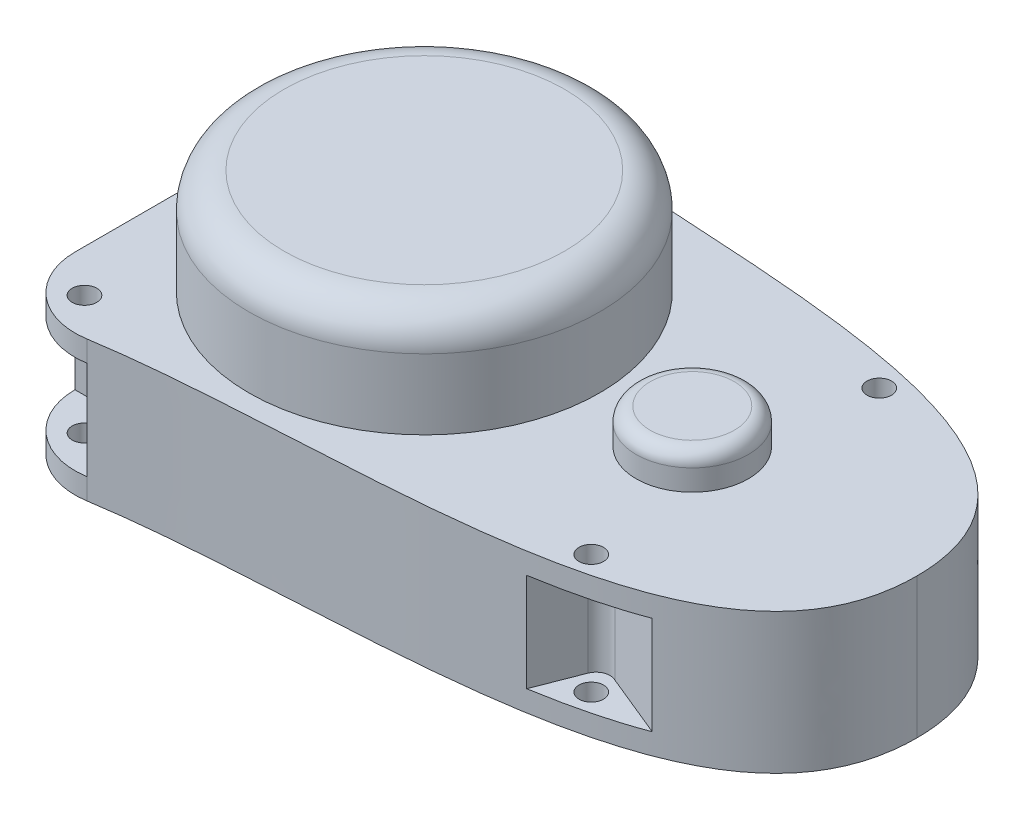
from build123d import *

# Parameters (mm, degrees)
BOSS_EXTRUDE2_DEPTH = 20
CUT_EXTRUDE1_START  = 3
CUT_EXTRUDE1_DEPTH  = 14
SKETCH3_3_R         = 1.75
CUT_EXTRUDE2_DEPTH  = 20
CUT_EXTRUDE3_START  = 3
CUT_EXTRUDE3_DEPTH  = 14
SKETCH4_3_R         = 1.75
CUT_EXTRUDE4_DEPTH  = 20
SKETCH5_R           = 25
BOSS_EXTRUDE3_DEPTH = 15
SKETCH5_3_R         = 8
BOSS_EXTRUDE4_DEPTH = 5
FILLET1_R           = 5
FILLET2_R           = 2


with BuildPart() as part:
    # Sketch2 → Boss-Extrude2 (new body)
    with BuildSketch(Plane(origin=(0, 0, 0), x_dir=(1, 0, 0), z_dir=(0, 1, 0))):
        with BuildLine():
            ThreePointArc((-46.431276572, 29.876188881), (-54.492794688, 27.605499138), (-58, 20))
            Line((-58, 20), (-58, -20))
            ThreePointArc((-58, -20), (-54.492794688, -27.605499138), (-46.431276572, -29.876188881))
            add(Edge.make_bspline(
                [(-46.431276572, -29.876188881), (-13.909309772, -24.710433965), (42, -31.730945936), (42, 31.730945936), (-13.909309772, 24.710433965), (-46.431276572, 29.876188881)],
                knots=[0, 0, 0, 0, 1, 1, 2, 2, 2, 2], degree=3))
        make_face()
    extrude(amount=BOSS_EXTRUDE2_DEPTH)

    # Sketch3 → Cut-Extrude1 (cut)
    with BuildSketch(Plane(origin=(0, 0, 0), x_dir=(1, 0, 0), z_dir=(0, 1, 0)).offset(CUT_EXTRUDE1_START)):
        with BuildLine():
            ThreePointArc((-46.431276572, 29.876188881), (-54.492794688, 27.605499138), (-58, 20))
            Line((-58, 20), (-49.70739476, 20))
            ThreePointArc((-49.70739476, 20), (-48.408835822, 20.478900172), (-47.732156984, 21.686255314))
            Line((-47.732156984, 21.686255314), (-46.431276572, 29.876188881))
        make_face()
        with BuildLine():
            Line((-49.70739476, -20), (-58, -20))
            ThreePointArc((-58, -20), (-54.492794688, -27.605499138), (-46.431276572, -29.876188881))
            Line((-46.431276572, -29.876188881), (-47.732156984, -21.686255314))
            ThreePointArc((-47.732156984, -21.686255314), (-48.408835822, -20.478900172), (-49.70739476, -20))
        make_face()
    extrude(amount=CUT_EXTRUDE1_DEPTH, mode=Mode.SUBTRACT)

    # Sketch3_3 → Cut-Extrude2 (cut)
    with BuildSketch(Plane(origin=(0, 0, 0), x_dir=(1, 0, 0), z_dir=(0, 1, 0))):
        with Locations((-51.979872901, 24.661924698)):
            Circle(SKETCH3_3_R)
        with Locations((-51.979872901, -24.661924698)):
            Circle(SKETCH3_3_R)
    extrude(amount=CUT_EXTRUDE2_DEPTH, mode=Mode.SUBTRACT)

    # Sketch4 → Cut-Extrude3 (cut)
    with BuildSketch(Plane(origin=(0, 0, 0), x_dir=(1, 0, 0), z_dir=(0, 1, 0)).offset(CUT_EXTRUDE3_START)):
        with BuildLine():
            Line((13.558094658, -18.415384316), (11.112598696, -24.715384316))
            add(Edge.make_bspline(
                [(11.112598695, -24.715384316), (16.304251166, -23.843854524), (21.135081496, -22.680661048), (25.361920748, -21.06959966)],
                knots=[0.510512009, 0.510512009, 0.510512009, 0.510512009, 0.655795995, 0.655795995, 0.655795995, 0.655795995], degree=3))
            Line((25.361920749, -21.06959966), (16.361920749, -17.373449023))
            ThreePointArc((16.361920749, -17.373449023), (14.725878749, -17.264380548), (13.558094658, -18.415384316))
        make_face()
        with BuildLine():
            add(Edge.make_bspline(
                [(11.112598695, 24.715384316), (16.304251166, 23.843854524), (21.135081496, 22.680661048), (25.361920748, 21.06959966)],
                knots=[0.510512009, 0.510512009, 0.510512009, 0.510512009, 0.655795995, 0.655795995, 0.655795995, 0.655795995], degree=3))
            Line((11.112598696, 24.715384316), (13.558094658, 18.415384316))
            ThreePointArc((13.558094658, 18.415384316), (14.725878749, 17.264380548), (16.361920749, 17.373449023))
            Line((16.361920749, 17.373449023), (25.361920749, 21.06959966))
        make_face()
    extrude(amount=CUT_EXTRUDE3_DEPTH, mode=Mode.SUBTRACT)

    # Sketch4_3 → Cut-Extrude4 (cut)
    with BuildSketch(Plane(origin=(0, 0, 0), x_dir=(1, 0, 0), z_dir=(0, 1, 0))):
        with Locations((16.128298142, 20.529949963)):
            Circle(SKETCH4_3_R)
        with Locations((16.128298142, -20.529949963)):
            Circle(SKETCH4_3_R)
    extrude(amount=CUT_EXTRUDE4_DEPTH, mode=Mode.SUBTRACT)

    # Sketch5 → Boss-Extrude3 (add)
    with BuildSketch(Plane(origin=(0, 20, 0), x_dir=(1, 0, 0), z_dir=(0, 1, 0))):
        with Locations((-28.2, 0)):
            Circle(SKETCH5_R)
    extrude(amount=BOSS_EXTRUDE3_DEPTH)

    # Sketch5_3 → Boss-Extrude4 (add)
    with BuildSketch(Plane(origin=(0, 20, 0), x_dir=(1, 0, 0), z_dir=(0, 1, 0))):
        with Locations((10, 0)):
            Circle(SKETCH5_3_R)
    extrude(amount=BOSS_EXTRUDE4_DEPTH)

    # Fillet1
    fillet1_edges = [part.edges().sort_by_distance(p)[0] for p in [
        (-53.2, 35, 0),
    ]]
    fillet(fillet1_edges, radius=FILLET1_R)

    # Fillet2
    fillet2_edges = [part.edges().sort_by_distance(p)[0] for p in [
        (2, 25, 0),
    ]]
    fillet(fillet2_edges, radius=FILLET2_R)


solid = part.part
